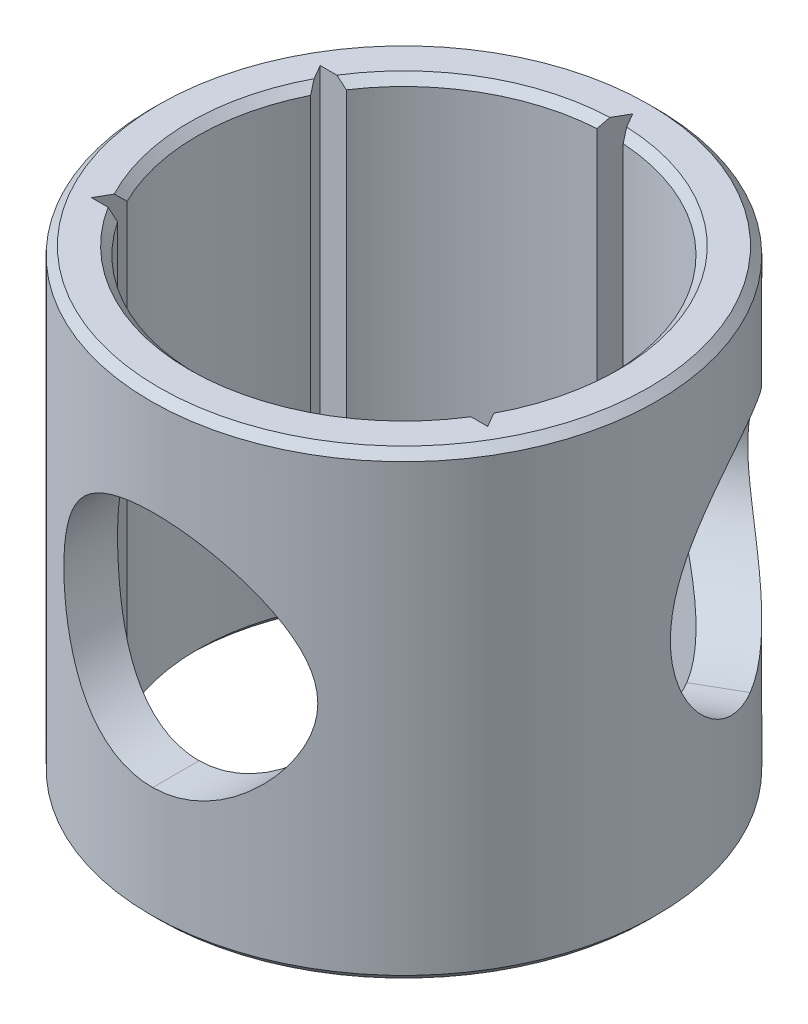
from build123d import *

# Parameters (mm, degrees)
SKIZZE1_R                       = 15.925
SKIZZE1_R_2                     = 13
AUFSATZ_LINEAR_AUSTRAGEN1_DEPTH = 29
SCHNITT_LINEAR_AUSTRAGEN1_DEPTH = 30
KREISMUSTER1_COUNT              = 6
SCHNITT_LINEAR_AUSTRAGEN2_DEPTH = 40
KREISMUSTER2_COUNT              = 2
KREISMUSTER2_ANGLE              = 120
FASE1_SIZE                      = 0.5


with BuildPart() as part:
    # Skizze1 → Aufsatz-Linear austragen1 (new body)
    with BuildSketch(Plane(origin=(0, 0, 0), x_dir=(1, 0, 0), z_dir=(0, 1, 0))):
        Circle(SKIZZE1_R)
        Circle(SKIZZE1_R_2, mode=Mode.SUBTRACT)
    extrude(amount=AUFSATZ_LINEAR_AUSTRAGEN1_DEPTH)

    # Skizze2 → Schnitt-Linear austragen1 (cut)
    with BuildSketch(Plane(origin=(0, 29, 0), x_dir=(1, 0, 0), z_dir=(0, 1, 0))):
        Polygon((0, 14.4), (-1.212435565, 12.3), (1.212435565, 12.3), align=None)
    schnitt_linear_austragen1 = extrude(amount=-SCHNITT_LINEAR_AUSTRAGEN1_DEPTH, mode=Mode.SUBTRACT)

    # Kreismuster1: Schnitt-Linear austragen1 ×6 about axis, 2 skipped
    kreismuster1_axis = Axis((0, 0, 0), (0, 1, 0))
    add([schnitt_linear_austragen1.rotate(kreismuster1_axis, i * 360 / KREISMUSTER1_COUNT) for i in range(1, KREISMUSTER1_COUNT) if i not in (3, 5)], mode=Mode.SUBTRACT)

    # Skizze4 → Schnitt-Linear austragen2 (cut)
    with BuildSketch(Plane.XY):
        with BuildLine():
            add(Edge.make_bspline(
                [(0.111060025, 22.5), (0.639300879, 22.5), (1.155677394, 22.445248159), (2.167064865, 22.237091412), (2.666545115, 22.080942317), (3.605989664, 21.688290409), (4.050194176, 21.451853076), (4.893446314, 20.905032787), (5.285125911, 20.59917097), (5.827575177, 20.099915553), (6.001199871, 19.926426342), (6.334425397, 19.564892818), (6.494571043, 19.37611554), (6.948382185, 18.793025727), (7.216655866, 18.38234153), (7.678212596, 17.504279407), (7.873119073, 17.03067888), (8.076117024, 16.289899143), (8.129271849, 16.037247788), (8.201601993, 15.517995542), (8.219931994, 15.254449012), (8.219373836, 14.733612639), (8.20081659, 14.474222401), (8.128221535, 13.95741094), (8.073943437, 13.70074198), (7.93793444, 13.20732613), (7.855909742, 12.96790589), (7.667704426, 12.500856046), (7.560934415, 12.272187735), (7.21175202, 11.609192865), (6.943084909, 11.199742989), (6.492879889, 10.621927107), (6.33479349, 10.435548798), (6.002244708, 10.074665182), (5.826984323, 9.899463309), (5.281731562, 9.397860606), (4.893307756, 9.09535099), (4.269746035, 8.690286916), (4.055023061, 8.563455953), (3.610577743, 8.327243912), (3.37961377, 8.217356465), (2.670822634, 7.9203305), (2.181766381, 7.766849611), (1.167202264, 7.556231906), (0.639334228, 7.5), (0.111060025, 7.5)],
                knots=[0, 0, 0, 0, 0.0625, 0.0625, 0.125, 0.125, 0.1875, 0.1875, 0.25, 0.25, 0.28125, 0.28125, 0.3125, 0.3125, 0.375, 0.375, 0.4375, 0.4375, 0.46875, 0.46875, 0.5, 0.5, 0.53125, 0.53125, 0.5625, 0.5625, 0.59375, 0.59375, 0.625, 0.625, 0.6875, 0.6875, 0.71875, 0.71875, 0.75, 0.75, 0.8125, 0.8125, 0.84375, 0.84375, 0.875, 0.875, 0.9375, 0.9375, 1, 1, 1, 1], degree=3))
            add(Edge.make_bspline(
                [(0.111060025, 7.5), (-0.390448327, 7.5), (-0.882142196, 7.549409538), (-1.846786236, 7.744105971), (-2.324101466, 7.892095257), (-3.218490264, 8.272179622), (-3.640194411, 8.504230194), (-4.435102241, 9.053198625), (-4.797963007, 9.363262244), (-5.290919717, 9.876843468), (-5.446890749, 10.056387063), (-5.742262296, 10.432848268), (-5.881325504, 10.629580644), (-6.265795523, 11.234360046), (-6.481935134, 11.660593869), (-6.747187548, 12.33706673), (-6.826058525, 12.570124504), (-6.961315382, 13.043113409), (-7.017489182, 13.281770455), (-7.15271788, 14.004210717), (-7.198868608, 14.494410817), (-7.199448336, 15.243418452), (-7.187937977, 15.494103354), (-7.14245933, 15.987185687), (-7.074564832, 16.475004835), (-6.962382705, 16.952612691), (-6.827561919, 17.425149461), (-6.748662835, 17.658846398), (-6.483025831, 18.337266083), (-6.266303639, 18.764968226), (-5.880230189, 19.372078328), (-5.740758514, 19.569163978), (-5.446184284, 19.944417008), (-5.290560393, 20.123537558), (-4.798392673, 20.636276772), (-4.435157623, 20.946735308), (-3.640693519, 21.495452919), (-3.220075027, 21.72683638), (-2.552756668, 22.010887407), (-2.324211269, 22.09497996), (-1.85413442, 22.241121071), (-1.612102928, 22.303083561), (-0.884217215, 22.450520557), (-0.390787068, 22.5), (0.111060025, 22.5)],
                knots=[0, 0, 0, 0, 0.0625, 0.0625, 0.125, 0.125, 0.1875, 0.1875, 0.25, 0.25, 0.28125, 0.28125, 0.3125, 0.3125, 0.375, 0.375, 0.40625, 0.40625, 0.4375, 0.4375, 0.5, 0.5, 0.53125, 0.53125, 0.5625, 0.59375, 0.59375, 0.625, 0.625, 0.6875, 0.6875, 0.71875, 0.71875, 0.75, 0.75, 0.8125, 0.8125, 0.875, 0.875, 0.90625, 0.90625, 0.9375, 0.9375, 1, 1, 1, 1], degree=3))
        make_face()
    schnitt_linear_austragen2 = extrude(amount=SCHNITT_LINEAR_AUSTRAGEN2_DEPTH, mode=Mode.SUBTRACT)

    # Kreismuster2: Schnitt-Linear austragen2 ×2 about axis
    kreismuster2_axis = Axis((0, 29, 0), (0, 1, 0))
    for i in range(1, KREISMUSTER2_COUNT):
        add(schnitt_linear_austragen2.rotate(kreismuster2_axis, i * KREISMUSTER2_ANGLE / (KREISMUSTER2_COUNT - 1)), mode=Mode.SUBTRACT)

    # Fase1
    fase1_edges = [part.edges().sort_by_distance(p)[0] for p in [
        (-6.5, 0, -11.258330249),
        (-15.925, 0, 0),
        (-13, 0, 0),
        (0, 0, 13),
        (11.258330249, 0, -6.5),
        (-13, 29, 0),
        (0, 29, 13),
        (11.258330249, 29, -6.5),
        (-15.925, 29, 0),
        (-6.5, 29, -11.258330249),
    ]]
    chamfer(fase1_edges, length=FASE1_SIZE)


solid = part.part
